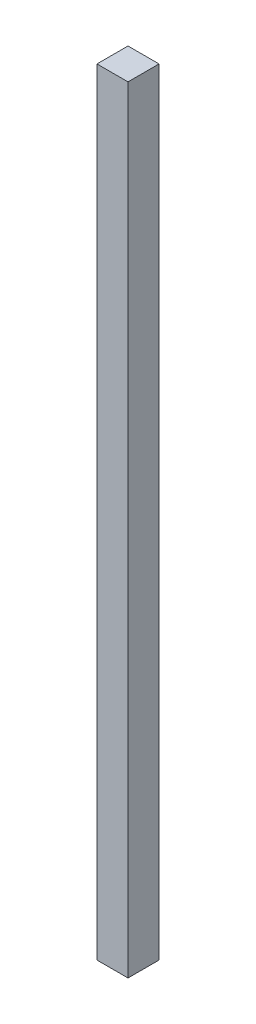
from build123d import *

# Parameters (mm, degrees)
SKETCH1_W           = 20
SKETCH1_H           = 20
BOSS_EXTRUDE1_DEPTH = 500


with BuildPart() as part:
    # Sketch1 → Boss-Extrude1 (new body)
    with BuildSketch(Plane(origin=(0, 0, 0), x_dir=(1, 0, 0), z_dir=(0, 1, 0))):
        with Locations((10, -10)):
            Rectangle(SKETCH1_W, SKETCH1_H)
    extrude(amount=BOSS_EXTRUDE1_DEPTH)


solid = part.part
